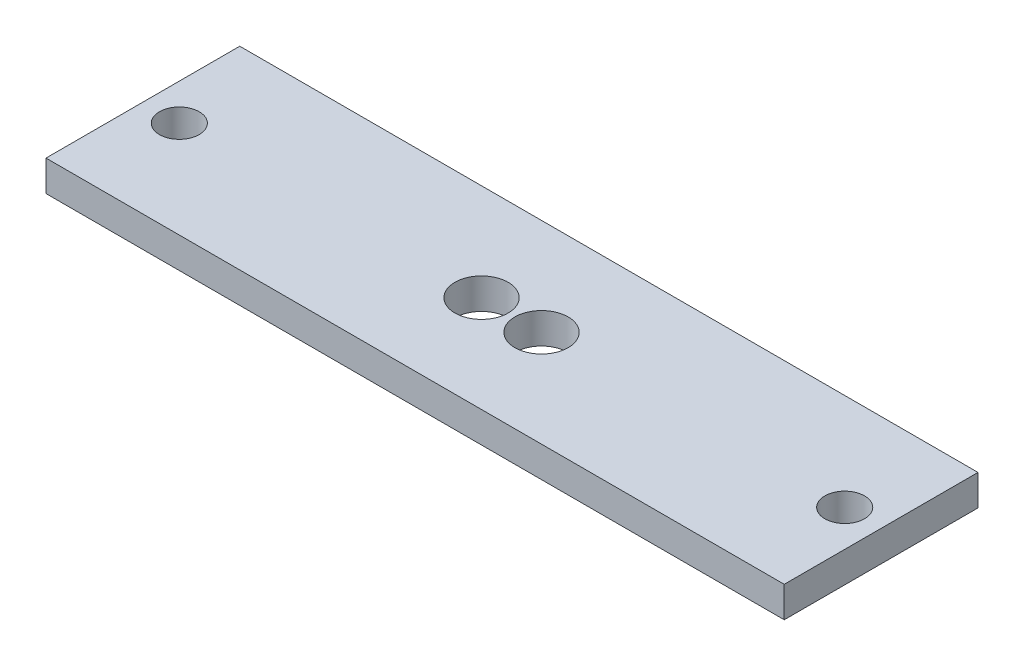
from build123d import *

# Parameters (mm, degrees)
SKETCH1_W           = 76.2
SKETCH1_H           = 20
SKETCH1_R           = 2.75
SKETCH1_R_2         = 2.049665702
BOSS_EXTRUDE1_DEPTH = 3.175


with BuildPart() as part:
    # Sketch1 → Boss-Extrude1 (new body)
    with BuildSketch(Plane(origin=(0, 0, 0), x_dir=(1, 0, 0), z_dir=(0, 1, 0))):
        with Locations((0, 0.475545855)):
            Rectangle(SKETCH1_W, SKETCH1_H)
        with Locations((3.048, 0.475545855)):
            Circle(SKETCH1_R, mode=Mode.SUBTRACT)
        with Locations((-3.143696082, 0.475545855)):
            Circle(SKETCH1_R, mode=Mode.SUBTRACT)
        with Locations((-34.340354519, 0.475545855)):
            Circle(SKETCH1_R_2, mode=Mode.SUBTRACT)
        with Locations((34.340354519, 0.475545855)):
            Circle(SKETCH1_R_2, mode=Mode.SUBTRACT)
    extrude(amount=BOSS_EXTRUDE1_DEPTH)


solid = part.part
